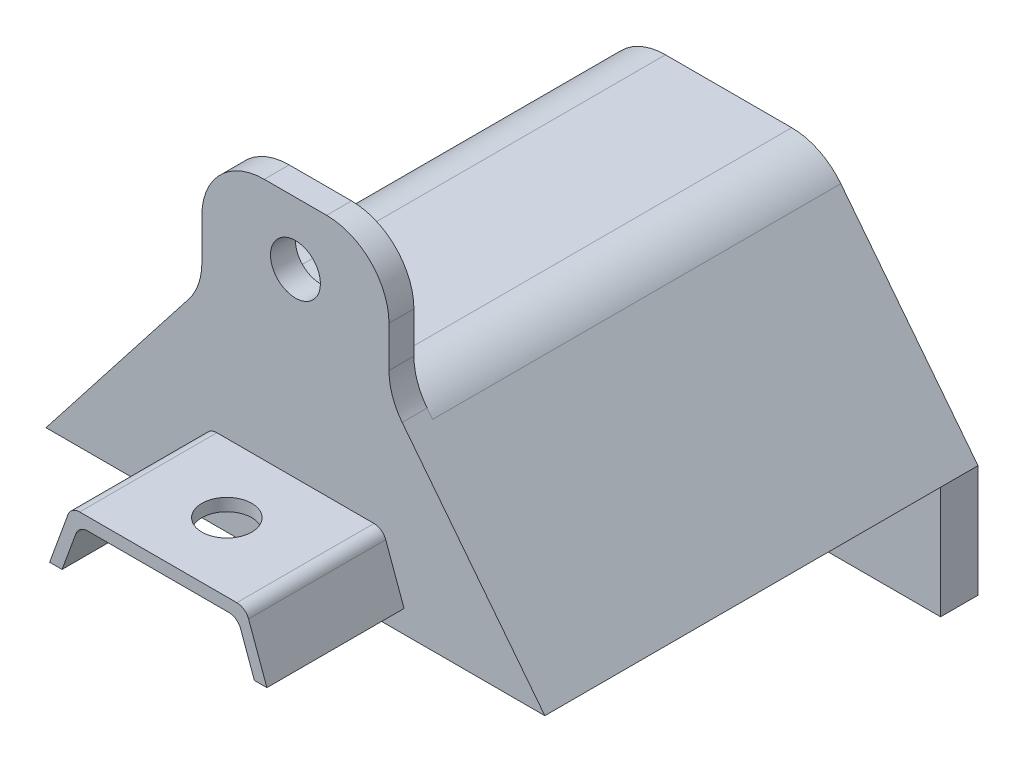
from build123d import *

# Parameters (mm, degrees)
SKETCH1_W               = 40
SKETCH1_H               = 25
SKETCH1_R               = 2.5
BOSS_EXTRUDE1_DEPTH     = 34.73
BOSS_EXTRUDE2_DEPTH     = 11
FILLET3_R               = 1
SKETCH5_W               = 15
SKETCH5_H               = 2
BOSS_EXTRUDE3_DEPTH     = 10
SKETCH8_R               = 2
CUT_EXTRUDE4_DEPTH      = 12
CUT_EXTRUDE4_DEPTH_BACK = 35.73
SKETCH10_W              = 40
SKETCH10_H              = 9
CUT_EXTRUDE5_DEPTH      = 22
CUT_EXTRUDE7_DEPTH      = 35.73
SKETCH7_R               = 2
CUT_EXTRUDE9_DEPTH      = 22
CUT_EXTRUDE8_DEPTH      = 22
FILLET7_R               = 5
FILLET8_R               = 5
FILLET9_R               = 5
FILLET10_R              = 5
FILLET11_R              = 5
FILLET12_R              = 5
FILLET13_R              = 5
FILLET14_R              = 5
FILLET15_R              = 5
FILLET16_R              = 5
SKETCH15_W              = 40
SKETCH15_H              = 9
CUT_EXTRUDE10_DEPTH     = 9.73


with BuildPart() as part:
    # Sketch1 → Boss-Extrude1 (new body)
    with BuildSketch(Plane.XY):
        with Locations((20, 12.5)):
            Rectangle(SKETCH1_W, SKETCH1_H)
        with Locations((10, 5)):
            Circle(SKETCH1_R, mode=Mode.SUBTRACT)
        with Locations((30, 5)):
            Circle(SKETCH1_R, mode=Mode.SUBTRACT)
    extrude(amount=BOSS_EXTRUDE1_DEPTH)

    # Sketch2 → Boss-Extrude2 (add)
    with BuildSketch(Plane.XY.offset(34.73)):
        Polygon((27, 15.5), (13, 15.5), (11.289899283, 10.801536896), (12.289899283, 10.801536896), (13.636029766, 14.5), (26.363970234, 14.5), (27.710100717, 10.801536896), (28.710100717, 10.801536896), align=None)
    extrude(amount=BOSS_EXTRUDE2_DEPTH)

    # Fillet3
    fillet3_edges = [part.edges().sort_by_distance(p)[0] for p in [
        (13, 15.5, 40.23),
        (13.636029766, 14.5, 40.23),
        (26.363970234, 14.5, 40.23),
        (27, 15.5, 40.23),
    ]]
    fillet(fillet3_edges, radius=FILLET3_R)

    # Sketch5 → Boss-Extrude3 (add)
    with BuildSketch(Plane(origin=(0, 25, 0), x_dir=(1, 0, 0), z_dir=(0, 1, 0))):
        with Locations((20, -33.73)):
            Rectangle(SKETCH5_W, SKETCH5_H)
    extrude(amount=BOSS_EXTRUDE3_DEPTH)

    # Sketch8 → Cut-Extrude4 (cut, two sides)
    with BuildSketch(Plane.XY.offset(34.73)) as cut_extrude4_sk:
        with Locations((20, 30)):
            Circle(SKETCH8_R)
    extrude(amount=CUT_EXTRUDE4_DEPTH, mode=Mode.SUBTRACT)
    extrude(cut_extrude4_sk.sketch, amount=-CUT_EXTRUDE4_DEPTH_BACK, mode=Mode.SUBTRACT)

    # Sketch10 → Cut-Extrude5 (cut)
    with BuildSketch(Plane.XY.offset(34.73)):
        with Locations((20, 4.5)):
            Rectangle(SKETCH10_W, SKETCH10_H)
    extrude(amount=-CUT_EXTRUDE5_DEPTH, mode=Mode.SUBTRACT)

    # Sketch12 → Cut-Extrude7 (cut, through all)
    with BuildSketch(Plane.XY.offset(34.73)):
        Polygon((12.5, 25), (0, 9), (0, 25), align=None)
        Polygon((27.5, 25), (40, 9), (40, 25), align=None)
    extrude(amount=-CUT_EXTRUDE7_DEPTH, mode=Mode.SUBTRACT)

    # Sketch7 → Cut-Extrude9 (cut)
    with BuildSketch(Plane.XZ.offset(-14.5)):
        with Locations((20, 40.23)):
            Circle(SKETCH7_R)
    extrude(amount=-CUT_EXTRUDE9_DEPTH, mode=Mode.SUBTRACT)

    # Sketch14 → Cut-Extrude8 (cut)
    with BuildSketch(Plane(origin=(0, 0, 0), x_dir=(-1, 0, 0), z_dir=(0, 0, -1))):
        Polygon((-36.656713145, 10.5), (-26.5, 23.5), (-13.5, 23.5), (-3.343286855, 10.5), align=None)
    extrude(amount=-CUT_EXTRUDE8_DEPTH, mode=Mode.SUBTRACT)

    # Fillet7
    fillet7_edges = [part.edges().sort_by_distance(p)[0] for p in [
        (27.5, 25, 16.365),
    ]]
    fillet(fillet7_edges, radius=FILLET7_R)

    # Fillet8
    fillet8_edges = [part.edges().sort_by_distance(p)[0] for p in [
        (27.5, 25, 33.73),
    ]]
    fillet(fillet8_edges, radius=FILLET8_R)

    # Fillet9
    fillet9_edges = [part.edges().sort_by_distance(p)[0] for p in [
        (12.5, 25, 16.365),
    ]]
    fillet(fillet9_edges, radius=FILLET9_R)

    # Fillet10
    fillet10_edges = [part.edges().sort_by_distance(p)[0] for p in [
        (12.5, 25, 33.73),
    ]]
    fillet(fillet10_edges, radius=FILLET10_R)

    # Fillet11
    fillet11_edges = [part.edges().sort_by_distance(p)[0] for p in [
        (3.343286855, 10.5, 11),
    ]]
    fillet(fillet11_edges, radius=FILLET11_R)

    # Fillet12
    fillet12_edges = [part.edges().sort_by_distance(p)[0] for p in [
        (36.656713145, 10.5, 11),
    ]]
    fillet(fillet12_edges, radius=FILLET12_R)

    # Fillet13
    fillet13_edges = [part.edges().sort_by_distance(p)[0] for p in [
        (26.5, 23.5, 11),
    ]]
    fillet(fillet13_edges, radius=FILLET13_R)

    # Fillet14
    fillet14_edges = [part.edges().sort_by_distance(p)[0] for p in [
        (13.5, 23.5, 11),
    ]]
    fillet(fillet14_edges, radius=FILLET14_R)

    # Fillet15
    fillet15_edges = [part.edges().sort_by_distance(p)[0] for p in [
        (27.5, 35, 33.73),
    ]]
    fillet(fillet15_edges, radius=FILLET15_R)

    # Fillet16
    fillet16_edges = [part.edges().sort_by_distance(p)[0] for p in [
        (12.5, 35, 33.73),
    ]]
    fillet(fillet16_edges, radius=FILLET16_R)

    # Sketch15 → Cut-Extrude10 (cut)
    with BuildSketch(Plane.XY.offset(12.73)):
        with Locations((20, 4.5)):
            Rectangle(SKETCH15_W, SKETCH15_H)
    extrude(amount=-CUT_EXTRUDE10_DEPTH, mode=Mode.SUBTRACT)


solid = part.part
